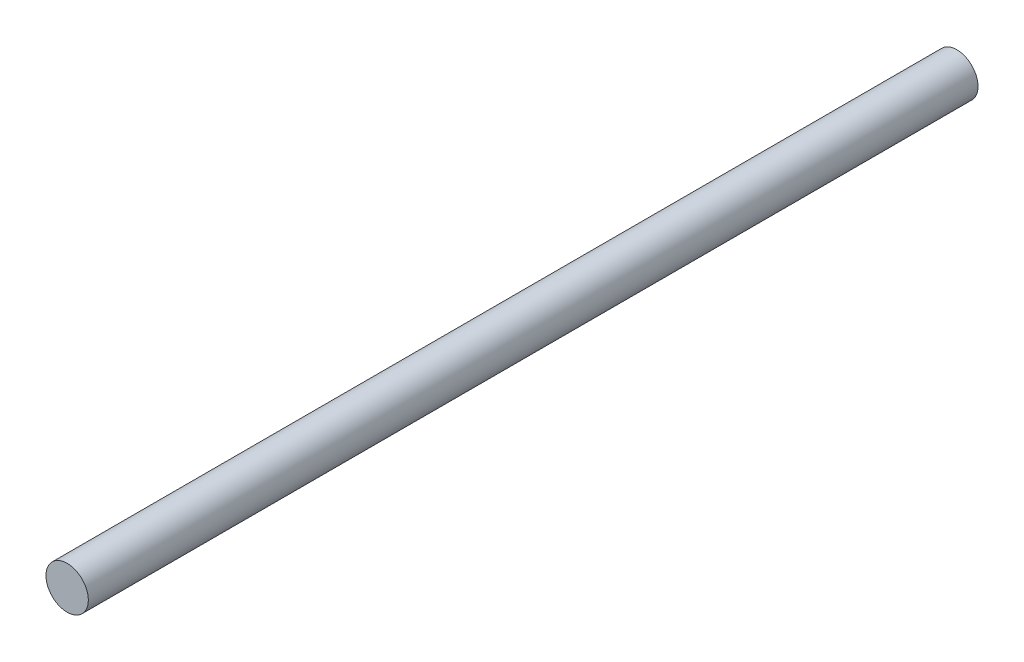
from build123d import *

# Parameters (mm, degrees)
SKETCH_1_R      = 1.5
EXTRUDE_1_DEPTH = 63


with BuildPart() as part:
    # ｽｹｯﾁ1 → ﾎﾞｽ - 押し出し1 (new body)
    with BuildSketch(Plane.XY):
        Circle(SKETCH_1_R)
    extrude(amount=EXTRUDE_1_DEPTH)


solid = part.part
